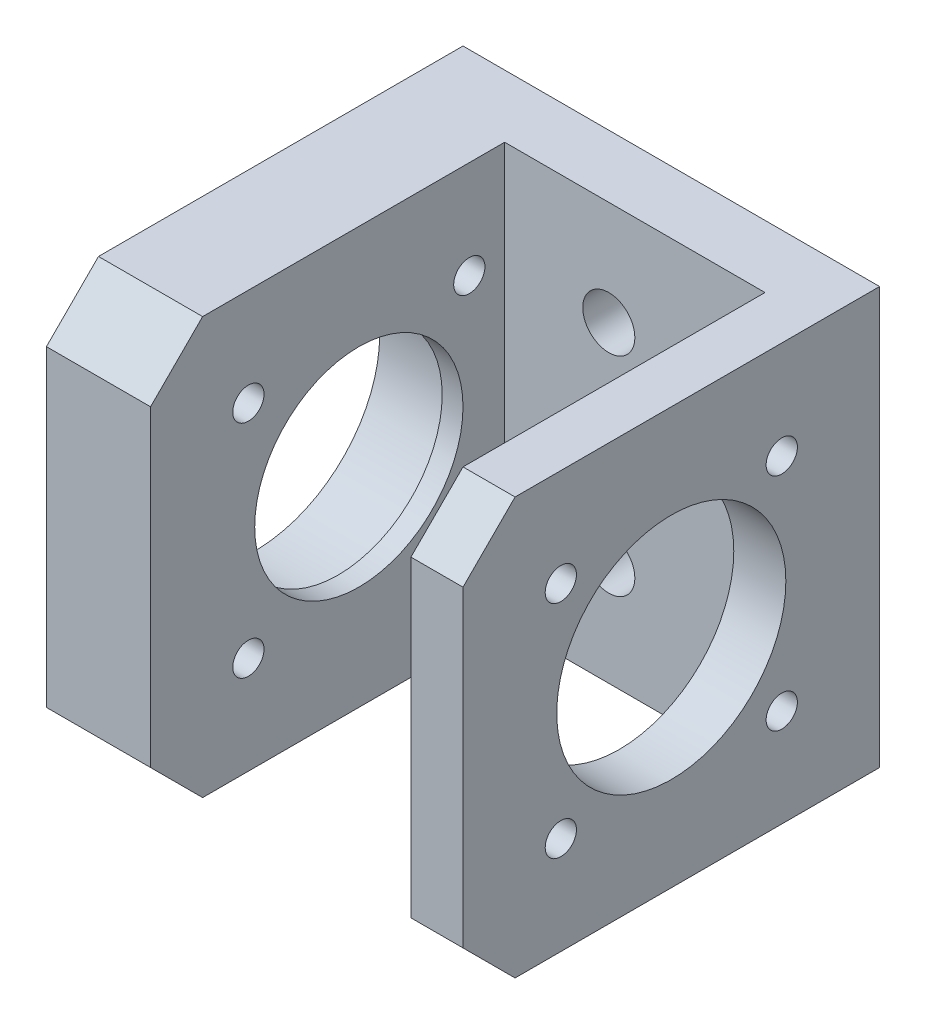
from build123d import *

# Parameters (mm, degrees)
SKETCH_1_W               = 40
SKETCH_1_H               = 40
EXTRUDE_1_DEPTH          = 40
SKETCH_2_W               = 25
SKETCH_2_H               = 40
CUT_EXTRUDE_1_DEPTH      = 34
SKETCH_3_R               = 2.5
CUT_EXTRUDE_2_DEPTH      = 7
CHAMFER_1_SIZE           = 5
SKETCH_5_R               = 12
CUT_EXTRUDE_4_DEPTH      = 8
CUT_EXTRUDE_5_REACH      = 34
SKETCH_7_R               = 10
CUT_EXTRUDE_6_REACH      = 42
SKETCH_4_R               = 11
SKETCH_9_R               = 1.5
CUT_EXTRUDE_7_DEPTH      = 41
PATTERN_CIRCULAR_1_COUNT = 4


with BuildPart() as part:
    # 草圖1 → 填料-伸長1 (new body)
    with BuildSketch(Plane.XY):
        Rectangle(SKETCH_1_W, SKETCH_1_H)
    extrude(amount=EXTRUDE_1_DEPTH)

    # 草圖2 → 除料-伸長1 (cut)
    with BuildSketch(Plane.XY.offset(40)):
        with Locations((2.5, 0)):
            Rectangle(SKETCH_2_W, SKETCH_2_H)
    extrude(amount=-CUT_EXTRUDE_1_DEPTH, mode=Mode.SUBTRACT)

    # 草圖3 → 除料-伸長2 (cut, through all)
    with BuildSketch(Plane.XY.offset(6)):
        with Locations((0, 10)):
            Circle(SKETCH_3_R)
        with Locations((0, -10)):
            Circle(SKETCH_3_R)
    extrude(amount=-CUT_EXTRUDE_2_DEPTH, mode=Mode.SUBTRACT)

    # 導角1
    chamfer_1_edges = [part.edges().sort_by_distance(p)[0] for p in [
        (-15, -20, 40),
        (-15, 20, 40),
        (17.5, -20, 40),
        (17.5, 20, 40),
    ]]
    chamfer(chamfer_1_edges, length=CHAMFER_1_SIZE)

    # 草圖5 → 除料-伸長4 (cut)
    with BuildSketch(Plane.ZY.offset(20)):
        with Locations((20, 0)):
            Circle(SKETCH_5_R)
    extrude(amount=-CUT_EXTRUDE_4_DEPTH, mode=Mode.SUBTRACT)

    # 草圖7 → 除料-伸長5 (cut, up to next)
    with BuildSketch(Plane.ZY.offset(12), mode=Mode.PRIVATE) as cut_extrude_5_sk1:
        with Locations((20, 0)):
            Circle(SKETCH_7_R)
    cut_extrude_5_tool1 = extrude(cut_extrude_5_sk1.sketch, amount=-CUT_EXTRUDE_5_REACH, mode=Mode.PRIVATE) & part.part
    add(cut_extrude_5_tool1.solids().sort_by_distance((-12, 0, 20))[0], mode=Mode.SUBTRACT)

    # 草圖4 → 除料-伸長6 (cut, up to next)
    with BuildSketch(Plane(origin=(20, 0, 0), x_dir=(0, 0, -1), z_dir=(1, 0, 0)), mode=Mode.PRIVATE) as cut_extrude_6_sk1:
        with Locations((-20, 0)):
            Circle(SKETCH_4_R)
    cut_extrude_6_tool1 = extrude(cut_extrude_6_sk1.sketch, amount=-CUT_EXTRUDE_6_REACH, mode=Mode.PRIVATE) & part.part
    add(cut_extrude_6_tool1.solids().sort_by_distance((20, 0, 20))[0], mode=Mode.SUBTRACT)

    # 草圖9 → 除料-伸長7 (cut, through all)
    with BuildSketch(Plane(origin=(20, 0, 0), x_dir=(0, 0, -1), z_dir=(1, 0, 0))):
        with Locations((-9.393398282, 10.606601718)):
            Circle(SKETCH_9_R)
    cut_extrude_7 = extrude(amount=-CUT_EXTRUDE_7_DEPTH, mode=Mode.SUBTRACT)

    # 環狀複製排列1: 除料-伸長7 ×4 about axis
    pattern_circular_1_axis = Axis((0, 0, 20), (1, 0, 0))
    for i in range(1, PATTERN_CIRCULAR_1_COUNT):
        add(cut_extrude_7.rotate(pattern_circular_1_axis, i * 360 / PATTERN_CIRCULAR_1_COUNT), mode=Mode.SUBTRACT)


solid = part.part
